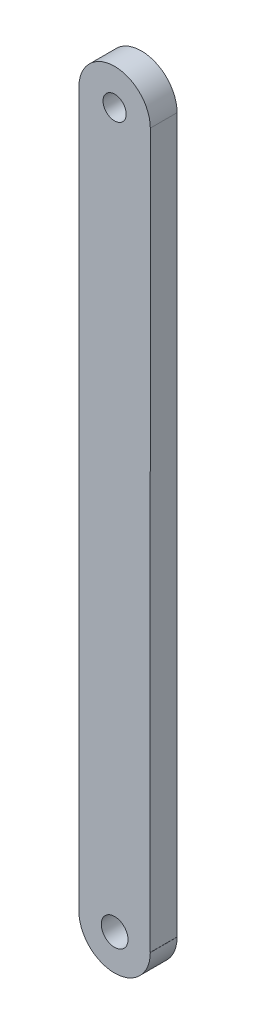
from build123d import *

# Parameters (mm, degrees)
MODEL_R             = 1.5
MODEL_R_2           = 1.3
BOSS_EXTRUDE1_DEPTH = 3


with BuildPart() as part:
    # Model → Boss-Extrude1 (new body)
    with BuildSketch(Plane.XY):
        with BuildLine():
            Line((47.500099999, 80.00015), (47.500099999, 4.9999e-05))
            ThreePointArc((47.500099999, 4.9999e-05), (51.499999999, -3.99985), (55.499899998, 4.9999e-05))
            Line((55.499899998, 4.9999e-05), (55.483779921, 0))
            Line((55.483779921, 0), (55.499899998, 80.000050001))
            ThreePointArc((55.499899998, 80.000050001), (51.500049998, 84), (47.500099999, 80.00015))
        make_face()
        with Locations((51.500099998, 4.9998e-05)):
            Circle(MODEL_R, mode=Mode.SUBTRACT)
        with Locations((51.500099998, 80.000049998)):
            Circle(MODEL_R_2, mode=Mode.SUBTRACT)
    extrude(amount=BOSS_EXTRUDE1_DEPTH)


solid = part.part
